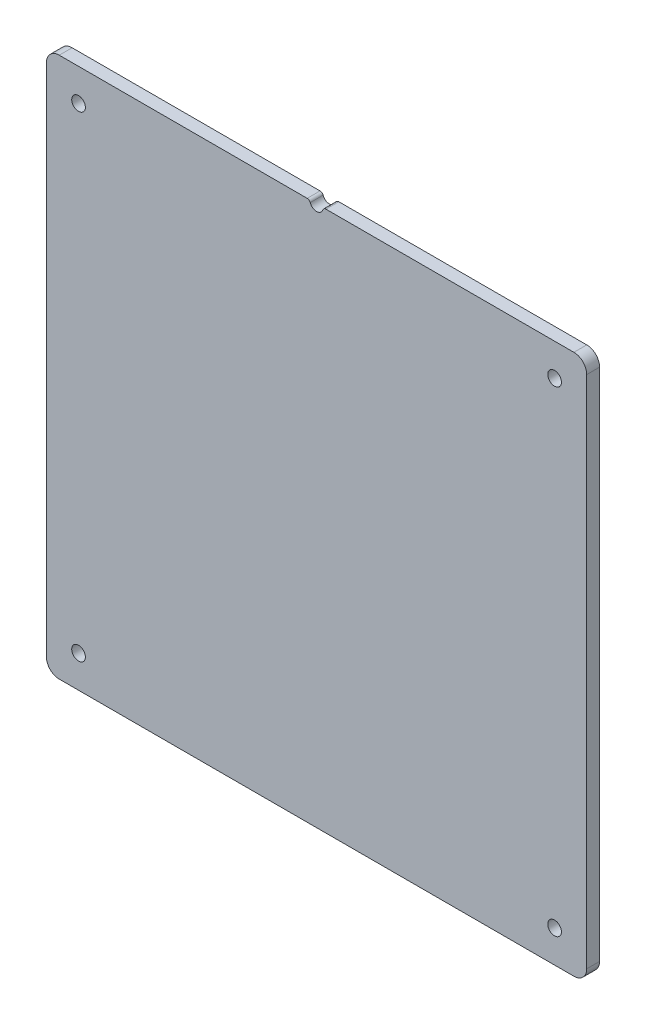
from build123d import *

# Parameters (mm, degrees)
SKETCH1_W               = 266.7
SKETCH1_H               = 266.7
BOSS_EXTRUDE1_DEPTH     = 6.35
F_1_4_CLEARANCE_HOLE1_D = 6.7564
FILLET1_R               = 6.35
SKETCH4_R               = 3.302
CUT_EXTRUDE1_DEPTH      = 7.35
FILLET2_R               = 1.5875


with BuildPart() as part:
    # Sketch1 → Boss-Extrude1 (new body)
    with BuildSketch(Plane.XY):
        Rectangle(SKETCH1_W, SKETCH1_H)
    extrude(amount=BOSS_EXTRUDE1_DEPTH)

    # 1/4 Clearance Hole1 (through all)
    with Locations(Plane.XY.offset(6.35)):
        with Locations((-117.475, 117.475), (-117.475, -117.475), (117.475, -117.475), (117.475, 117.475)):
            Hole(F_1_4_CLEARANCE_HOLE1_D / 2)

    # Fillet1
    fillet1_edges = [part.edges().sort_by_distance(p)[0] for p in [
        (133.35, -133.35, 3.175),
        (-133.35, -133.35, 3.175),
        (-133.35, 133.35, 3.175),
        (133.35, 133.35, 3.175),
    ]]
    fillet(fillet1_edges, radius=FILLET1_R)

    # Sketch4 → Cut-Extrude1 (cut, through all)
    with BuildSketch(Plane.XY.offset(6.35)):
        with Locations((0, 133.35)):
            Circle(SKETCH4_R)
    extrude(amount=-CUT_EXTRUDE1_DEPTH, mode=Mode.SUBTRACT)

    # Fillet2
    fillet2_edges = [part.edges().sort_by_distance(p)[0] for p in [
        (-3.302, 133.35, 3.175),
        (3.302, 133.35, 3.175),
    ]]
    fillet(fillet2_edges, radius=FILLET2_R)


solid = part.part
